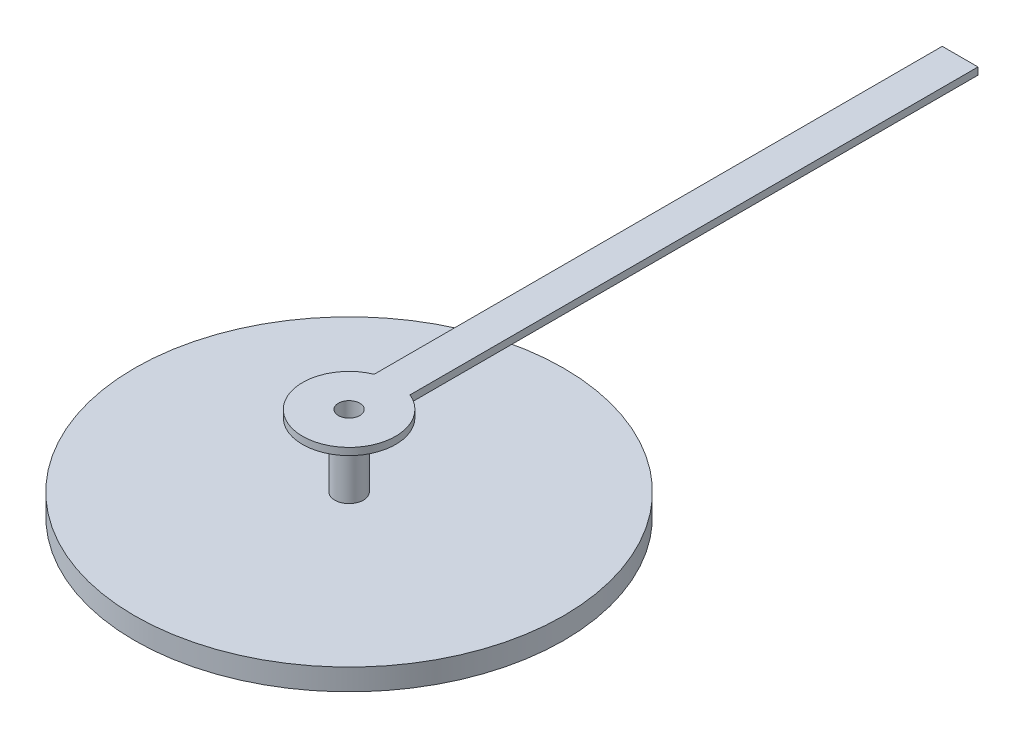
from build123d import *

# Parameters (mm, degrees)
BOSS_EXTRUDE1_DEPTH = 0.1
SKETCH2_R           = 0.2
BOSS_EXTRUDE2_DEPTH = 1
SKETCH3_R           = 3
BOSS_EXTRUDE3_DEPTH = 0.3
SKETCH4_R           = 0.15
CUT_EXTRUDE1_DEPTH  = 2.3


with BuildPart() as part:
    # Sketch1 → Boss-Extrude1 (new body)
    with BuildSketch(Plane(origin=(0, 0, 0), x_dir=(1, 0, 0), z_dir=(0, 1, 0))):
        with BuildLine():
            Line((-0.25, 8.545435606), (0.25, 8.545435606))
            Line((0.25, 8.545435606), (0.25, 0.601234649))
            ThreePointArc((0.25, 0.601234649), (0, -0.651139849), (-0.25, 0.601234649))
            Line((-0.25, 0.601234649), (-0.25, 8.545435606))
        make_face()
    extrude(amount=BOSS_EXTRUDE1_DEPTH)

    # Sketch2 → Boss-Extrude2 (add)
    with BuildSketch(Plane.XZ.offset(-0.1)):
        Circle(SKETCH2_R)
    extrude(amount=BOSS_EXTRUDE2_DEPTH)

    # Sketch3 → Boss-Extrude3 (add)
    with BuildSketch(Plane.XZ.offset(0.9)):
        Circle(SKETCH3_R)
    extrude(amount=BOSS_EXTRUDE3_DEPTH)

    # Sketch4 → Cut-Extrude1 (cut, through all)
    with BuildSketch(Plane(origin=(0, 0.1, 0), x_dir=(1, 0, 0), z_dir=(0, 1, 0))):
        Circle(SKETCH4_R)
    extrude(amount=-CUT_EXTRUDE1_DEPTH, mode=Mode.SUBTRACT)


solid = part.part
